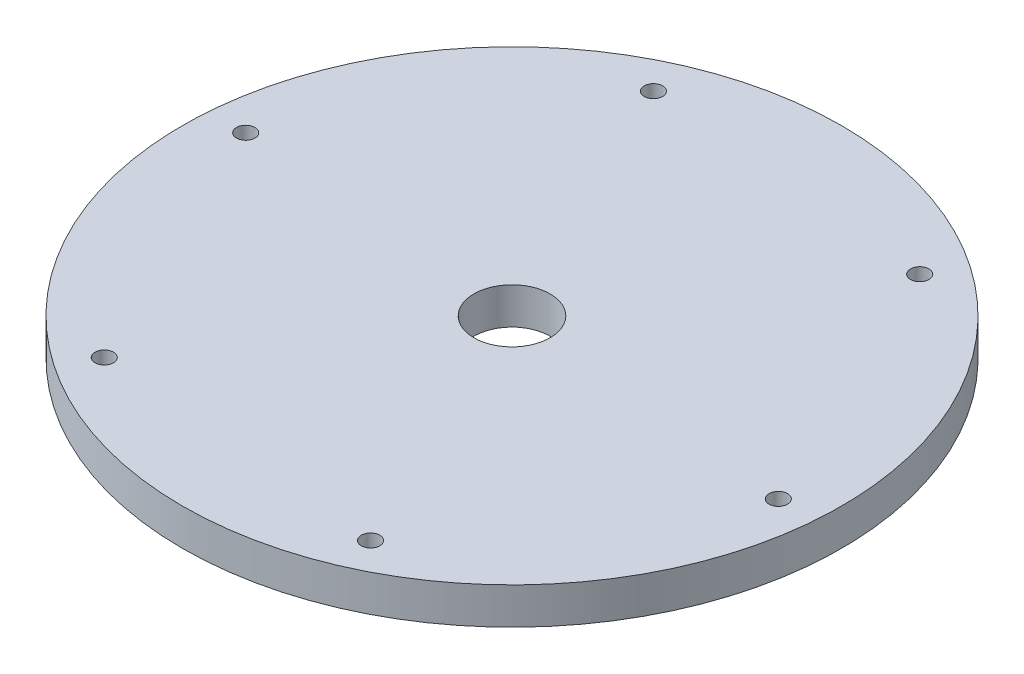
from build123d import *

# Parameters (mm, degrees)
SKETCH1_R           = 53.5432
SKETCH1_R_2         = 6.1849
SKETCH1_R_3         = 1.4986
BOSS_EXTRUDE1_DEPTH = 5.9563


with BuildPart() as part:
    # Sketch1 → Boss-Extrude1 (new body)
    with BuildSketch(Plane(origin=(0, 0, 0), x_dir=(1, 0, 0), z_dir=(0, 1, 0))):
        Circle(SKETCH1_R)
        Circle(SKETCH1_R_2, mode=Mode.SUBTRACT)
        with Locations((47.389642634, -4.125319175)):
            Circle(SKETCH1_R_3, mode=Mode.SUBTRACT)
        with Locations((20.122190112, -43.103293985)):
            Circle(SKETCH1_R_3, mode=Mode.SUBTRACT)
        with Locations((-27.267452522, -38.97797481)):
            Circle(SKETCH1_R_3, mode=Mode.SUBTRACT)
        with Locations((-47.389642634, 4.125319175)):
            Circle(SKETCH1_R_3, mode=Mode.SUBTRACT)
        with Locations((-20.122190112, 43.103293985)):
            Circle(SKETCH1_R_3, mode=Mode.SUBTRACT)
        with Locations((27.267452522, 38.97797481)):
            Circle(SKETCH1_R_3, mode=Mode.SUBTRACT)
    extrude(amount=BOSS_EXTRUDE1_DEPTH)


solid = part.part
